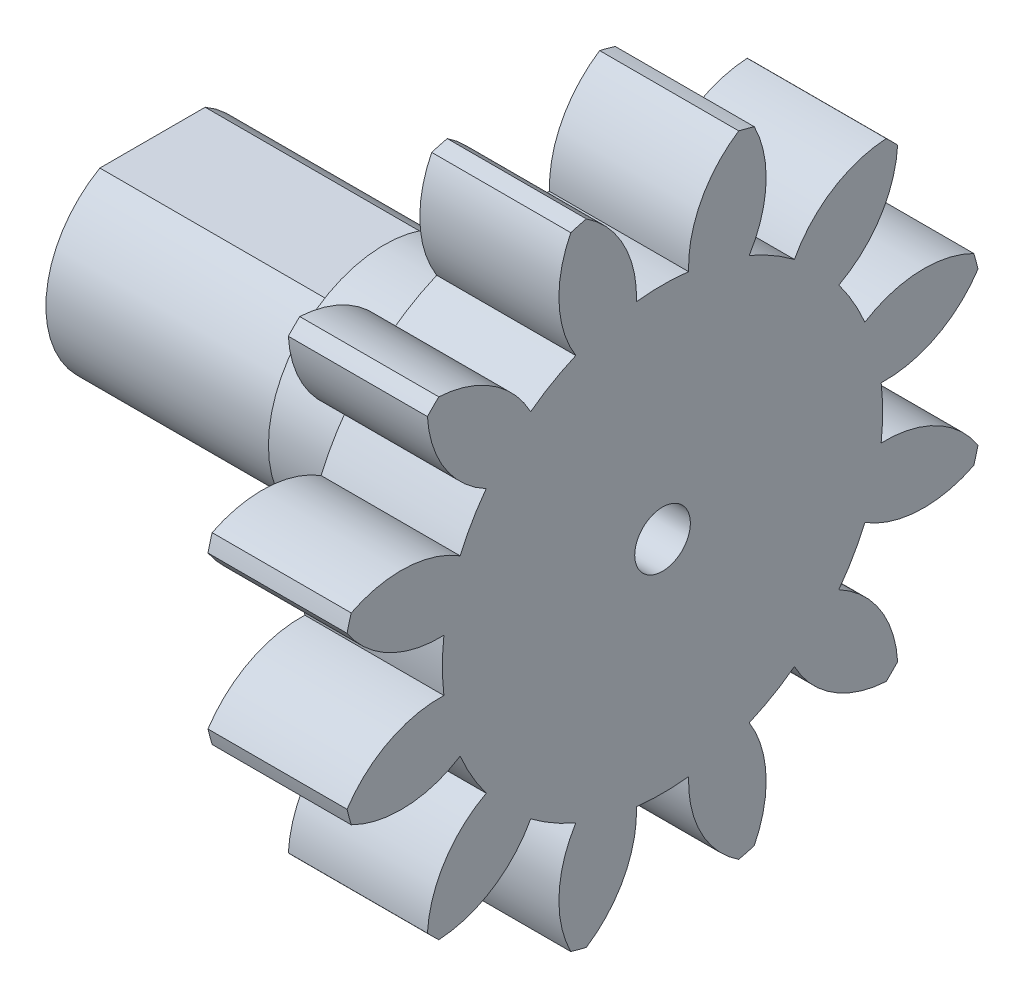
from build123d import *

# Parameters (mm, degrees)
BASPROSKE_W         = 3
BASPROSKE_H         = 7
TOOTHCUT_DEPTH      = 11.344080433
TEETHCUTS_COUNT     = 12
HUBNEAONESKE_R      = 2.5
HUBNEARONE_DEPTH    = 8
BORSKE_R            = 0.6
BORE_DEPTH          = 15.0000508
CUT_EXTRUDE_4_DEPTH = 5
SKETCH_2_R          = 3
SKETCH_2_R_2        = 2.5
EXTRUDE_1_DEPTH     = 0.5
SKETCH_3_OUTSIDE_W  = 20.042
SKETCH_3_OUTSIDE_H  = 20.042
SKETCH_3_OUTSIDE_R  = 2.3
CUT_EXTRUDE_5_DEPTH = 5


with BuildPart() as part:
    # BasProSke → Base-Revolve (revolve)
    with BuildSketch(Plane(origin=(0, 0, 0), x_dir=(1, 0, 0), z_dir=(0, 1, 0)), mode=Mode.PRIVATE) as base_revolve_sk:
        with Locations((1.5, 3.5)):
            Rectangle(BASPROSKE_W, BASPROSKE_H)
    revolve(base_revolve_sk.sketch.rotate(Axis((-10, 0, 0), (1, 0, 0)), 180), axis=Axis((-10, 0, 0), (1, 0, 0)))

    # TooCutSke → ToothCut (cut, through all)
    with BuildSketch(Plane(origin=(0, 0, 0), x_dir=(0, 0, -1), z_dir=(1, 0, 0))):
        with BuildLine():
            ThreePointArc((0.562207301, 4.715604304), (0, 4.749), (-0.562207301, 4.715604304))
            ThreePointArc((-0.562207301, 4.715604304), (-0.837528627, 5.917009812), (-1.672850686, 6.823328788))
            ThreePointArc((-1.672850686, 6.823328788), (0, 7.0254), (1.672850686, 6.823328788))
            ThreePointArc((1.672850686, 6.823328788), (0.837528627, 5.917009812), (0.562207301, 4.715604304))
        make_face()
    toothcut = extrude(amount=TOOTHCUT_DEPTH, mode=Mode.SUBTRACT)

    # TeethCuts: ToothCut ×12 about axis
    teethcuts_axis = Axis((0, 0, 0), (1, 0, 0))
    for i in range(1, TEETHCUTS_COUNT):
        add(toothcut.rotate(teethcuts_axis, i * 360 / TEETHCUTS_COUNT), mode=Mode.SUBTRACT)

    # HubNeaOneSke → HubNearOne (add)
    with BuildSketch(Plane.ZY):
        with Locations(Location((0, 0, 0), (0, 0, 180))):
            Circle(HUBNEAONESKE_R)
    extrude(amount=HUBNEARONE_DEPTH)

    # BorSke → Bore (cut, symmetric)
    with BuildSketch(Plane(origin=(0, 0, 0), x_dir=(0, 0, -1), z_dir=(1, 0, 0))):
        with Locations(Location((0, 0, 0), (0, 0, 180))):
            Circle(BORSKE_R)
    extrude(amount=BORE_DEPTH, both=True, mode=Mode.SUBTRACT)

    # 草图1 → 切除-拉伸4 (cut)
    with BuildSketch(Plane.ZY.offset(8)):
        with BuildLine():
            Line((-1.5, 2), (1.5, 2))
            ThreePointArc((1.5, 2), (0, 2.5), (-1.5, 2))
        make_face()
    extrude(amount=-CUT_EXTRUDE_4_DEPTH, mode=Mode.SUBTRACT)

    # 草图2 → 凸台-拉伸1 (add)
    with BuildSketch(Plane.ZY):
        with Locations(Location((0, 0, 0), (0, 0, 180))):
            Circle(SKETCH_2_R)
        with Locations(Location((0, 0, 0), (0, 0, 126.869897646))):
            Circle(SKETCH_2_R_2, mode=Mode.SUBTRACT)
    extrude(amount=EXTRUDE_1_DEPTH)

    # 草图3 outside → 切除-拉伸5 (cut)
    with BuildSketch(Plane.ZY.offset(8)):
        Rectangle(SKETCH_3_OUTSIDE_W, SKETCH_3_OUTSIDE_H)
        Circle(SKETCH_3_OUTSIDE_R, mode=Mode.SUBTRACT)
    extrude(amount=-CUT_EXTRUDE_5_DEPTH, mode=Mode.SUBTRACT)


solid = part.part
